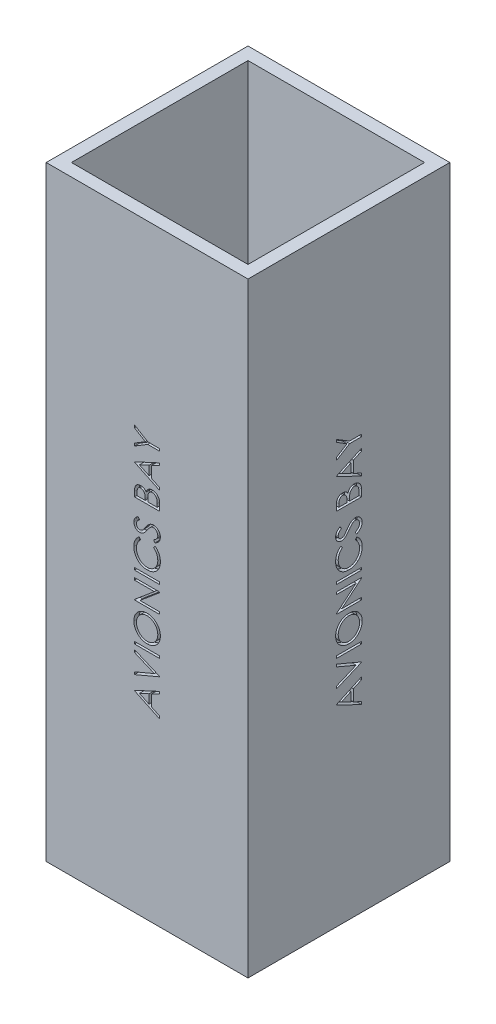
from build123d import *

# Parameters (mm, degrees)
SKETCH1_W           = 101.6
SKETCH1_H           = 101.6
SKETCH1_W_2         = 88.9
SKETCH1_H_2         = 88.9
BOSS_EXTRUDE1_DEPTH = 304.8
SKETCH6_W           = 12.7
SKETCH6_H           = 1.13974359
CUT_EXTRUDE1_DEPTH  = 2.54
CIRPATTERN1_COUNT   = 4


with BuildPart() as part:
    # Sketch1 → Boss-Extrude1 (new body)
    with BuildSketch(Plane(origin=(0, 0, 0), x_dir=(1, 0, 0), z_dir=(0, 1, 0))):
        Rectangle(SKETCH1_W, SKETCH1_H)
        Rectangle(SKETCH1_W_2, SKETCH1_H_2, mode=Mode.SUBTRACT)
    extrude(amount=BOSS_EXTRUDE1_DEPTH)

    # Sketch6 → Cut-Extrude1 (cut)
    with BuildSketch(Plane.ZY.offset(50.8)):
        Polygon((-6.35, 96.878205128), (6.35, 102.73974359), (6.35, 101.50078125), (2.279487179, 99.623257212), (2.279487179, 93.866025641), (6.35, 91.935076122), (6.35, 90.691025641), (-6.35, 96.715384615), align=None)
        Polygon((-3.874619391, 96.784074519), (0.976923077, 94.484234776), (0.976923077, 99.022856571), align=None, mode=Mode.SUBTRACT)
        Polygon((-6.35, 103.716666667), (-6.35, 104.937820513), (3.658373397, 109.171153846), (-6.35, 113.404487179), (-6.35, 114.625641026), (6.35, 109.252564103), (6.35, 109.08974359), align=None)
        with Locations((0, 117.637820513)):
            Rectangle(SKETCH6_W, SKETCH6_H)
        with BuildLine():
            add(Edge.make_bspline(
                [(-6.675641026, 126.918589744), (-6.669785071, 127.153776225), (-6.658283492, 127.615701878), (-6.567334124, 128.293959972), (-6.41764098, 128.94342251), (-6.206242297, 129.564462859), (-5.932190469, 130.154719051), (-5.599295982, 130.715858123), (-5.205535771, 131.246198399), (-4.756691829, 131.742089333), (-4.26513446, 132.194456748), (-3.738912975, 132.591411503), (-3.184643364, 132.926280299), (-2.60229672, 133.200406882), (-1.99323266, 133.415614417), (-1.354037691, 133.564081648), (-0.688898346, 133.658928646), (-0.235229152, 133.67001636), (-0.005088141, 133.675641026)],
                knots=[0, 0, 0, 0, 0.000705368, 0.001385402, 0.0020488, 0.002702076, 0.003349741, 0.00399766, 0.004656078, 0.005327949, 0.006001364, 0.006657226, 0.007302086, 0.007940532, 0.008585026, 0.009236039, 0.009906328, 0.010596447, 0.010596447, 0.010596447, 0.010596447], degree=3))
            add(Edge.make_bspline(
                [(-0.005088141, 133.675641026), (0.223356266, 133.670014467), (0.673646657, 133.658923867), (1.334584132, 133.564004689), (1.969850898, 133.414951949), (2.578031024, 133.203071444), (3.159194899, 132.928734508), (3.71388411, 132.593372735), (4.241511135, 132.197171355), (4.736454933, 131.746724924), (5.189213913, 131.254231132), (5.588564969, 130.730032068), (5.923579539, 130.175777236), (6.200766497, 129.597210358), (6.411489139, 128.98978834), (6.56490218, 128.357931404), (6.658807614, 127.698196983), (6.669968316, 127.248780089), (6.675641026, 127.020352564)],
                knots=[0, 0, 0, 0, 0.000685036, 0.001350284, 0.001998823, 0.002640075, 0.00327852, 0.003923381, 0.004581277, 0.005254856, 0.005928271, 0.006585666, 0.00722835, 0.007867883, 0.008506734, 0.009153393, 0.009816123, 0.010501158, 0.010501158, 0.010501158, 0.010501158], degree=3))
            add(Edge.make_bspline(
                [(6.675641026, 127.020352564), (6.670018965, 126.790212892), (6.658936386, 126.336546337), (6.563935289, 125.670569095), (6.415376844, 125.03093271), (6.203071175, 124.41946635), (5.928688652, 123.835829034), (5.594118477, 123.278879305), (5.19712685, 122.750852685), (4.746579565, 122.256126919), (4.256099934, 121.803465543), (3.730558494, 121.40882438), (3.180265837, 121.074178969), (2.603694821, 120.800717734), (2.003632729, 120.584220981), (1.376076825, 120.436520641), (0.724604903, 120.340958758), (0.281037815, 120.329946601), (0.055969551, 120.324358974)],
                knots=[0, 0, 0, 0, 0.000690119, 0.001360408, 0.002013897, 0.002657552, 0.003298299, 0.003945339, 0.004603236, 0.005276814, 0.005950229, 0.006602529, 0.007245213, 0.007879059, 0.008513962, 0.009155077, 0.009810248, 0.010485118, 0.010485118, 0.010485118, 0.010485118], degree=3))
            add(Edge.make_bspline(
                [(0.055969551, 120.324358974), (-0.095097562, 120.326298937), (-0.395326011, 120.33015439), (-0.841156245, 120.37656996), (-1.279816632, 120.443922419), (-1.710059786, 120.540449359), (-2.130832502, 120.666693407), (-2.545036699, 120.815653621), (-2.948474782, 120.997589631), (-3.343057946, 121.203259411), (-3.722635205, 121.4328094), (-4.081426835, 121.686358548), (-4.422443595, 121.955001171), (-4.736848437, 122.249508342), (-5.033787705, 122.560173729), (-5.308698135, 122.892036987), (-5.564058671, 123.243073131), (-5.794183909, 123.614792623), (-6.002315626, 123.998036078), (-6.180920628, 124.393103243), (-6.33421348, 124.794628516), (-6.45845876, 125.204492525), (-6.556546433, 125.621606869), (-6.623338831, 126.046881916), (-6.669872784, 126.479978863), (-6.673710006, 126.771757077), (-6.675641026, 126.918589744)],
                knots=[0, 0, 0, 0, 0.000453023, 0.000900331, 0.00134327, 0.001783953, 0.002221843, 0.002660465, 0.003103469, 0.003548398, 0.003994743, 0.004433047, 0.004865726, 0.005295975, 0.005724256, 0.006154227, 0.006587795, 0.007025471, 0.007464852, 0.007895214, 0.008325184, 0.00875333, 0.009179133, 0.00960951, 0.010044159, 0.010484467, 0.010484467, 0.010484467, 0.010484467], degree=3))
        make_face()
        with BuildLine():
            add(Edge.make_bspline(
                [(-5.373076923, 126.974559295), (-5.371612874, 126.854036083), (-5.368698771, 126.61414187), (-5.330103131, 126.257532198), (-5.275488499, 125.905504237), (-5.196168901, 125.558739209), (-5.093572448, 125.216509883), (-4.969833028, 124.878664322), (-4.820275395, 124.546360887), (-4.652079665, 124.22001472), (-4.461036223, 123.907163348), (-4.258166746, 123.607053335), (-4.035933534, 123.327490795), (-3.799142721, 123.064635323), (-3.545739327, 122.819140613), (-3.277387483, 122.591114952), (-2.992926494, 122.380745328), (-2.693527038, 122.19056345), (-2.380860728, 122.021316425), (-2.060904396, 121.869782467), (-1.729897889, 121.744166597), (-1.389906788, 121.644660114), (-1.042429358, 121.560201909), (-0.685572416, 121.507223472), (-0.320566176, 121.468247545), (-0.073887757, 121.465494862), (0.05088141, 121.464102564)],
                knots=[0, 0, 0, 0, 0.000361401, 0.000719348, 0.001074863, 0.001429731, 0.001785501, 0.002146095, 0.002508248, 0.002878058, 0.003246738, 0.003607323, 0.00396412, 0.004317168, 0.004668001, 0.005021764, 0.005372855, 0.005728561, 0.006084895, 0.00643885, 0.006789913, 0.007145683, 0.007501125, 0.007861666, 0.008227207, 0.008601324, 0.008601324, 0.008601324, 0.008601324], degree=3))
            add(Edge.make_bspline(
                [(0.05088141, 121.464102564), (0.234345869, 121.468739076), (0.595277215, 121.477860528), (1.124266852, 121.557384132), (1.63314324, 121.680852383), (2.118873279, 121.859858024), (2.583622971, 122.088215042), (3.025583679, 122.366764243), (3.444625029, 122.698056552), (3.837627676, 123.074154181), (4.19619396, 123.485407025), (4.511375607, 123.921887717), (4.776641272, 124.380142983), (4.998397407, 124.857531559), (5.165459253, 125.358129306), (5.284574271, 125.878726583), (5.361776101, 126.419334899), (5.369274234, 126.787728134), (5.373076923, 126.974559295)],
                knots=[0, 0, 0, 0, 0.000550108, 0.001082232, 0.001601154, 0.002118677, 0.00263181, 0.003152009, 0.003682843, 0.004231661, 0.004781633, 0.005317521, 0.005844193, 0.006367833, 0.006893982, 0.007424089, 0.007968455, 0.008528619, 0.008528619, 0.008528619, 0.008528619], degree=3))
            add(Edge.make_bspline(
                [(5.373076923, 126.974559295), (5.371352914, 127.100142838), (5.367933685, 127.349212721), (5.333446658, 127.719666375), (5.278253288, 128.083480379), (5.198393676, 128.43998253), (5.099767851, 128.789639923), (4.97743268, 129.131397518), (4.830782133, 129.465141802), (4.667344949, 129.792513872), (4.481684714, 130.106183548), (4.281550104, 130.404473162), (4.063238117, 130.683554059), (3.829627504, 130.946286203), (3.57700307, 131.19006041), (3.310282099, 131.417436835), (3.025217373, 131.624169109), (2.727044186, 131.813706266), (2.416657403, 131.985018365), (2.095821442, 132.132169161), (1.766257055, 132.257838985), (1.427722103, 132.3591431), (1.080978091, 132.438565908), (0.725528754, 132.493281802), (0.362093818, 132.531558287), (0.116280345, 132.534443183), (-0.007632212, 132.535897436)],
                knots=[0, 0, 0, 0, 0.00037666, 0.00074703, 0.001115112, 0.001479909, 0.001842294, 0.002204411, 0.002567866, 0.002935359, 0.003301431, 0.003660587, 0.004012239, 0.004363588, 0.004714421, 0.005064598, 0.005414184, 0.00576989, 0.006123991, 0.006476875, 0.006827938, 0.007181271, 0.007536139, 0.007894167, 0.008259708, 0.008631282, 0.008631282, 0.008631282, 0.008631282], degree=3))
            add(Edge.make_bspline(
                [(-0.007632212, 132.535897436), (-0.130697041, 132.534441969), (-0.374818801, 132.531554782), (-0.735719484, 132.493300659), (-1.088609709, 132.438506), (-1.432104078, 132.359538459), (-1.766290161, 132.257756476), (-2.090854054, 132.132253863), (-2.407005009, 131.984261543), (-2.713961172, 131.814414362), (-3.008510573, 131.623494815), (-3.290092515, 131.414870151), (-3.553442649, 131.184954519), (-3.804973342, 130.940256746), (-4.03965346, 130.674893764), (-4.256576238, 130.388819264), (-4.465515493, 130.089156128), (-4.650429047, 129.769127694), (-4.822051388, 129.44003162), (-4.968471586, 129.102031491), (-5.094225799, 128.759954443), (-5.196475173, 128.412432789), (-5.275184667, 128.059630794), (-5.330152005, 127.701753628), (-5.368685515, 127.340050484), (-5.371608475, 127.096776301), (-5.373076923, 126.974559295)],
                knots=[0, 0, 0, 0, 0.000369031, 0.00073204, 0.001087555, 0.001439943, 0.001788407, 0.002134718, 0.002482986, 0.00283486, 0.003186283, 0.003535331, 0.003885231, 0.004234241, 0.004587492, 0.004946738, 0.00531086, 0.005682608, 0.006054677, 0.006423813, 0.006786796, 0.007147444, 0.007509758, 0.007870298, 0.008233308, 0.008599795, 0.008599795, 0.008599795, 0.008599795], degree=3))
        make_face(mode=Mode.SUBTRACT)
        Polygon((6.35, 136.280769231), (-6.35, 136.280769231), (-6.35, 136.519911859), (3.645653045, 144.91025641), (-6.35, 144.91025641), (-6.35, 146.05), (6.35, 146.05), (6.35, 145.790504808), (-3.62275641, 137.420512821), (6.35, 137.420512821), align=None)
        with Locations((0, 149.876282051)):
            Rectangle(SKETCH6_W, SKETCH6_H)
        with BuildLine():
            Line((-4.01963141, 164.937179487), (-3.256410256, 163.939903846))
            add(Edge.make_bspline(
                [(-3.256410256, 163.939903846), (-3.341194225, 163.86876175), (-3.509619091, 163.727436708), (-3.746144204, 163.500084035), (-3.96766222, 163.263092265), (-4.175596423, 163.016791141), (-4.361589506, 162.755480687), (-4.540126766, 162.489117567), (-4.696442281, 162.208023627), (-4.887401238, 161.821298238), (-5.082322078, 161.313422851), (-5.249970827, 160.67630071), (-5.355686274, 160.010291597), (-5.36721364, 159.55602053), (-5.373076923, 159.324959936)],
                knots=[0, 0, 0, 0, 0.00033196, 0.000659444, 0.000983431, 0.001304932, 0.001625525, 0.001945168, 0.002266407, 0.002589534, 0.003238685, 0.003894034, 0.004563275, 0.005256052, 0.005256052, 0.005256052, 0.005256052], degree=3))
            add(Edge.make_bspline(
                [(-5.373076923, 159.324959936), (-5.371611116, 159.197657678), (-5.368693107, 158.944234648), (-5.330197138, 158.568138759), (-5.276090748, 158.199065687), (-5.195807431, 157.837255511), (-5.094306788, 157.483168771), (-4.973020274, 157.134490642), (-4.822961328, 156.796269264), (-4.657105476, 156.463826165), (-4.469772216, 156.145312206), (-4.265432984, 155.843944011), (-4.046387468, 155.560803099), (-3.811766703, 155.295730062), (-3.562803693, 155.048216165), (-3.296709232, 154.821376006), (-3.01632795, 154.612178829), (-2.721427006, 154.42181689), (-2.414752947, 154.250446937), (-2.09455485, 154.106351454), (-1.766315152, 153.980499435), (-1.427706865, 153.879347067), (-1.080980558, 153.799905176), (-0.72469984, 153.744982709), (-0.359540199, 153.706932881), (-0.112038264, 153.704028246), (0.012720353, 153.702564103)],
                knots=[0, 0, 0, 0, 0.000381746, 0.00075995, 0.001133062, 0.001500343, 0.001870765, 0.002237676, 0.002606812, 0.002979993, 0.003351741, 0.00371443, 0.004071661, 0.004424911, 0.004775707, 0.005123948, 0.005472996, 0.005824418, 0.006176292, 0.006525803, 0.006876866, 0.007230199, 0.007585067, 0.007943095, 0.008311168, 0.008685285, 0.008685285, 0.008685285, 0.008685285], degree=3))
            add(Edge.make_bspline(
                [(0.012720353, 153.702564103), (0.200426958, 153.707153439), (0.568963978, 153.716163992), (1.108848166, 153.796015543), (1.62655408, 153.918332475), (2.118576381, 154.098650853), (2.58901667, 154.325429822), (3.032169897, 154.608387446), (3.454528385, 154.937342282), (3.845862858, 155.315668985), (4.203321893, 155.730809638), (4.518103914, 156.176206293), (4.780503276, 156.650767193), (4.998856092, 157.149247901), (5.166701906, 157.675485571), (5.284863161, 158.228533553), (5.361941929, 158.807189083), (5.369321311, 159.202592333), (5.373076923, 159.403826122)],
                knots=[0, 0, 0, 0, 0.000562815, 0.001105012, 0.001633818, 0.002156121, 0.002673826, 0.003197534, 0.003730369, 0.00427735, 0.004827582, 0.005371763, 0.005910445, 0.006451621, 0.007001941, 0.007564319, 0.008146516, 0.008749895, 0.008749895, 0.008749895, 0.008749895], degree=3))
            add(Edge.make_bspline(
                [(5.373076923, 159.403826122), (5.366949065, 159.625541593), (5.354887975, 160.06193068), (5.252710128, 160.701894661), (5.087037112, 161.314527297), (4.855178937, 161.899861539), (4.553770606, 162.456247255), (4.188381165, 162.984555137), (3.755534929, 163.485231121), (3.425033292, 163.786298346), (3.256410256, 163.939903846)],
                knots=[0, 0, 0, 0, 0.000664826, 0.001308536, 0.001938654, 0.00256556, 0.003192755, 0.00383282, 0.004489298, 0.005173128, 0.005173128, 0.005173128, 0.005173128], degree=3))
            Line((3.256410256, 163.939903846), (4.011999199, 164.937179487))
            add(Edge.make_bspline(
                [(4.011999199, 164.937179487), (4.115549426, 164.856919532), (4.322153882, 164.696784061), (4.613478666, 164.437535279), (4.887251894, 164.164230312), (5.142106353, 163.876166654), (5.379096924, 163.572836575), (5.598352345, 163.25426791), (5.798709025, 162.920732587), (5.982746472, 162.574879839), (6.144785206, 162.215912717), (6.288375195, 161.846991365), (6.407251844, 161.465853771), (6.507808151, 161.075708271), (6.579509323, 160.673031297), (6.636606518, 160.26250367), (6.670480805, 159.840282994), (6.673905521, 159.555682198), (6.675641026, 159.411458333)],
                knots=[0, 0, 0, 0, 0.00039295, 0.000784017, 0.001168988, 0.001552873, 0.001937104, 0.002323107, 0.002712292, 0.003103781, 0.003497718, 0.003893163, 0.004290641, 0.004694796, 0.005100972, 0.005516895, 0.005937967, 0.006370579, 0.006370579, 0.006370579, 0.006370579], degree=3))
            add(Edge.make_bspline(
                [(6.675641026, 159.411458333), (6.674690367, 159.274865599), (6.672810557, 159.00477038), (6.642358978, 158.60599491), (6.60081279, 158.217775574), (6.538255743, 157.841221932), (6.464434852, 157.474279108), (6.365479149, 157.120273558), (6.254629316, 156.775721795), (6.124345507, 156.442008102), (5.977329645, 156.11884862), (5.811171703, 155.807285647), (5.627268936, 155.507462478), (5.429675042, 155.216431379), (5.212043118, 154.938491576), (4.977395615, 154.671234498), (4.726523405, 154.413161513), (4.545621508, 154.253494627), (4.454667468, 154.173217147)],
                knots=[0, 0, 0, 0, 0.000409666, 0.000810065, 0.001199174, 0.001580615, 0.001954827, 0.00232143, 0.002682661, 0.003040299, 0.003395496, 0.003747176, 0.004098847, 0.004450261, 0.004801913, 0.005157073, 0.005516877, 0.005880706, 0.005880706, 0.005880706, 0.005880706], degree=3))
            add(Edge.make_bspline(
                [(4.454667468, 154.173217147), (4.296671895, 154.044644771), (3.982588209, 153.789052255), (3.473598494, 153.461901295), (2.942643322, 153.182795524), (2.386647308, 152.954609118), (1.80539431, 152.779335337), (1.199819394, 152.656106475), (0.571133136, 152.576587079), (0.143559958, 152.567459908), (-0.073778045, 152.562820513)],
                knots=[0, 0, 0, 0, 0.000610709, 0.001214046, 0.001811469, 0.002408161, 0.003014189, 0.003629886, 0.004260364, 0.004912143, 0.004912143, 0.004912143, 0.004912143], degree=3))
            add(Edge.make_bspline(
                [(-0.073778045, 152.562820513), (-0.302216405, 152.568463644), (-0.751654617, 152.579566151), (-1.41123439, 152.673893752), (-2.04315518, 152.825636241), (-2.646237339, 153.041162094), (-3.223652928, 153.31441294), (-3.770991014, 153.651966653), (-4.291751972, 154.049901712), (-4.77803407, 154.505097172), (-5.222676864, 155.004270075), (-5.613859375, 155.538826914), (-5.93940579, 156.107721407), (-6.211534722, 156.704686183), (-6.420701774, 157.33419137), (-6.567126194, 157.994893881), (-6.658265445, 158.685552229), (-6.669786913, 159.156767316), (-6.675641026, 159.39619391)],
                knots=[0, 0, 0, 0, 0.000685036, 0.001347765, 0.001994424, 0.002631723, 0.003265569, 0.003907406, 0.004557186, 0.005228594, 0.005902557, 0.006560016, 0.007211953, 0.007865497, 0.008525192, 0.009197944, 0.009893113, 0.01061119, 0.01061119, 0.01061119, 0.01061119], degree=3))
            add(Edge.make_bspline(
                [(-6.675641026, 159.39619391), (-6.673890031, 159.542114516), (-6.670424115, 159.830949658), (-6.636678167, 160.258230506), (-6.580304858, 160.674192872), (-6.5039791, 161.079274223), (-6.407862207, 161.47464568), (-6.288069769, 161.859567565), (-6.145448455, 162.233097302), (-5.982581524, 162.595113545), (-5.799438593, 162.943172484), (-5.598179886, 163.277055612), (-5.379822309, 163.595431829), (-5.142130377, 163.896646351), (-4.887075716, 164.181067708), (-4.617645938, 164.452915028), (-4.326927265, 164.704275096), (-4.12225087, 164.859402575), (-4.01963141, 164.937179487)],
                knots=[0, 0, 0, 0, 0.000437698, 0.00086638, 0.001284824, 0.001696468, 0.002102476, 0.00250481, 0.002905006, 0.003301261, 0.003695, 0.004084185, 0.004470188, 0.004852417, 0.005234401, 0.005615774, 0.005999895, 0.006386133, 0.006386133, 0.006386133, 0.006386133], degree=3))
        make_face()
        with BuildLine():
            Line((3.900060096, 166.23974359), (3.256410256, 167.313341346))
            add(Edge.make_bspline(
                [(3.256410256, 167.313341346), (3.423558168, 167.413193236), (3.743807115, 167.604505602), (4.176543433, 167.923643391), (4.544343259, 168.254325669), (4.845066949, 168.599001251), (5.081827195, 168.955566263), (5.249475293, 169.3263484), (5.354036118, 169.710098171), (5.366736432, 169.971260323), (5.373076923, 170.101642628)],
                knots=[0, 0, 0, 0, 0.000583841, 0.001118616, 0.00161028, 0.002064766, 0.002487434, 0.002889373, 0.003281209, 0.003671854, 0.003671854, 0.003671854, 0.003671854], degree=3))
            add(Edge.make_bspline(
                [(5.373076923, 170.101642628), (5.369901903, 170.212969551), (5.363607418, 170.433675437), (5.305569139, 170.759226871), (5.210618635, 171.073820423), (5.081902947, 171.374328835), (4.923683382, 171.652790602), (4.737112822, 171.900890196), (4.521537218, 172.110383999), (4.284942628, 172.284056896), (4.031233879, 172.418443722), (3.769823052, 172.52001459), (3.497123393, 172.576899748), (3.313472359, 172.58543586), (3.220793269, 172.58974359)],
                knots=[0, 0, 0, 0, 0.000333749, 0.000661658, 0.00098843, 0.001317806, 0.001640301, 0.001947123, 0.002245767, 0.002538865, 0.00282455, 0.003104744, 0.003377672, 0.003655722, 0.003655722, 0.003655722, 0.003655722], degree=3))
            add(Edge.make_bspline(
                [(3.220793269, 172.58974359), (3.115018322, 172.584508847), (2.900812519, 172.573907922), (2.584236292, 172.480481264), (2.269594656, 172.337822667), (2.074931876, 172.203739618), (1.974198718, 172.134354968)],
                knots=[0, 0, 0, 0, 0.000316704, 0.000641359, 0.000982872, 0.001349121, 0.001349121, 0.001349121, 0.001349121], degree=3))
            add(Edge.make_bspline(
                [(1.974198718, 172.134354968), (1.90144819, 172.077501361), (1.748717556, 171.958144324), (1.521566328, 171.752774984), (1.286785255, 171.513014926), (1.03922007, 171.242145649), (0.780927013, 170.93971279), (0.5098905, 170.605599338), (0.231649187, 170.236953825), (0.045281334, 169.978202783), (-0.05088141, 169.844691506)],
                knots=[0, 0, 0, 0, 0.00027693, 0.00058138, 0.000917785, 0.001283326, 0.001682064, 0.002110776, 0.002573803, 0.003067412, 0.003067412, 0.003067412, 0.003067412], degree=3))
            add(Edge.make_bspline(
                [(-0.05088141, 169.844691506), (-0.146053714, 169.711073006), (-0.328015911, 169.455604608), (-0.598069742, 169.098340609), (-0.844971783, 168.778864986), (-1.071046341, 168.498597698), (-1.276324078, 168.257662018), (-1.458833743, 168.054159355), (-1.623511235, 167.893273734), (-1.730341247, 167.803809198), (-1.778305288, 167.763641827)],
                knots=[0, 0, 0, 0, 0.000492118, 0.000940893, 0.001343419, 0.001703394, 0.002021005, 0.002292935, 0.002523226, 0.002710868, 0.002710868, 0.002710868, 0.002710868], degree=3))
            add(Edge.make_bspline(
                [(-1.778305288, 167.763641827), (-1.853061333, 167.707508002), (-2.000079127, 167.5971133), (-2.229805018, 167.451233986), (-2.464519473, 167.328213563), (-2.705073148, 167.229205123), (-2.949658139, 167.149140748), (-3.200110695, 167.093475469), (-3.454730594, 167.059164567), (-3.626042223, 167.055620349), (-3.711798878, 167.053846154)],
                knots=[0, 0, 0, 0, 0.000280379, 0.000551403, 0.000815399, 0.001074307, 0.001330956, 0.00158648, 0.001843028, 0.00210018, 0.00210018, 0.00210018, 0.00210018], degree=3))
            add(Edge.make_bspline(
                [(-3.711798878, 167.053846154), (-3.846164323, 167.058581987), (-4.112023245, 167.067952428), (-4.500388447, 167.147205364), (-4.871193366, 167.272281321), (-5.220681509, 167.44756559), (-5.540071901, 167.673310696), (-5.832239357, 167.935689886), (-6.081208535, 168.245304478), (-6.295348186, 168.588070847), (-6.464690808, 168.961284292), (-6.587413997, 169.354196894), (-6.660310029, 169.76398427), (-6.670480481, 170.041990806), (-6.675641026, 170.183052885)],
                knots=[0, 0, 0, 0, 0.000402767, 0.000796926, 0.001183901, 0.001574148, 0.001965141, 0.002354126, 0.002748285, 0.003152792, 0.003563783, 0.00397416, 0.004384892, 0.004807973, 0.004807973, 0.004807973, 0.004807973], degree=3))
            add(Edge.make_bspline(
                [(-6.675641026, 170.183052885), (-6.670549285, 170.332734281), (-6.660423439, 170.630402805), (-6.570190732, 171.067557559), (-6.426581296, 171.490168611), (-6.258089803, 171.828624484), (-6.090878214, 172.094077708), (-5.938243775, 172.296316487), (-5.762888377, 172.502369213), (-5.561115259, 172.710021438), (-5.336960086, 172.92132312), (-5.088525366, 173.135300953), (-4.818049902, 173.353957403), (-4.624912741, 173.494577906), (-4.525901442, 173.566666667)],
                knots=[0, 0, 0, 0, 0.00044863, 0.000892182, 0.001333063, 0.001784748, 0.002022602, 0.002273448, 0.002544149, 0.002833827, 0.003141576, 0.003468021, 0.003817263, 0.004184633, 0.004184633, 0.004184633, 0.004184633], degree=3))
            Line((-4.525901442, 173.566666667), (-3.744871795, 172.536318109))
            add(Edge.make_bspline(
                [(-3.744871795, 172.536318109), (-3.825026824, 172.474107404), (-3.97938667, 172.354304132), (-4.195483741, 172.172345372), (-4.393146913, 172.001104738), (-4.564381231, 171.83110024), (-4.722009393, 171.675435779), (-4.854569572, 171.521670798), (-4.966250039, 171.375739107), (-5.085651319, 171.192234038), (-5.200429634, 170.959775153), (-5.301248892, 170.67040125), (-5.361060256, 170.366971662), (-5.369038173, 170.160416239), (-5.373076923, 170.055849359)],
                knots=[0, 0, 0, 0, 0.000304354, 0.000586115, 0.000847462, 0.001088545, 0.001309821, 0.001511814, 0.001697025, 0.001860738, 0.002167928, 0.002472049, 0.002777898, 0.00309148, 0.00309148, 0.00309148, 0.00309148], degree=3))
            add(Edge.make_bspline(
                [(-5.373076923, 170.055849359), (-5.368752177, 169.924621874), (-5.360412313, 169.671562032), (-5.2669317, 169.31312815), (-5.124800726, 168.988656041), (-4.919849343, 168.710532372), (-4.675507819, 168.480889971), (-4.396853518, 168.312714045), (-4.089090687, 168.212164614), (-3.874507915, 168.199857539), (-3.765224359, 168.193589744)],
                knots=[0, 0, 0, 0, 0.000392785, 0.000757449, 0.001103592, 0.001449623, 0.001786259, 0.002103452, 0.002418835, 0.002746151, 0.002746151, 0.002746151, 0.002746151], degree=3))
            add(Edge.make_bspline(
                [(-3.765224359, 168.193589744), (-3.697198882, 168.195097723), (-3.560200307, 168.198134688), (-3.358759769, 168.236942195), (-3.158381362, 168.289413133), (-2.959770314, 168.369853596), (-2.75842921, 168.481873603), (-2.551514272, 168.628819859), (-2.337243251, 168.813934503), (-2.197879003, 168.955726853), (-2.124298878, 169.030588942)],
                knots=[0, 0, 0, 0, 0.00020378, 0.000410399, 0.000613447, 0.00082462, 0.001051213, 0.001303192, 0.001584654, 0.001899472, 0.001899472, 0.001899472, 0.001899472], degree=3))
            add(Edge.make_bspline(
                [(-2.124298878, 169.030588942), (-2.099490242, 169.058388779), (-2.0405506, 169.124434829), (-1.94405861, 169.245178902), (-1.825031408, 169.404628484), (-1.677757431, 169.5986199), (-1.506918983, 169.830730041), (-1.314700447, 170.10098443), (-1.094861782, 170.406370564), (-0.94116442, 170.623075802), (-0.859895833, 170.737660256)],
                knots=[0, 0, 0, 0, 0.000111766, 0.000265529, 0.000463461, 0.000708709, 0.000996201, 0.001328024, 0.001703617, 0.002125051, 0.002125051, 0.002125051, 0.002125051], degree=3))
            add(Edge.make_bspline(
                [(-0.859895833, 170.737660256), (-0.759597115, 170.875494759), (-0.565382548, 171.142392169), (-0.273589467, 171.522150989), (0.011792861, 171.866475445), (0.28892344, 172.176599914), (0.555762092, 172.455502879), (0.81531225, 172.700372837), (1.06587182, 172.912320821), (1.384920328, 173.143614136), (1.780392633, 173.37715182), (2.265139205, 173.577391189), (2.751276848, 173.704780047), (3.077597552, 173.721324346), (3.238601763, 173.729487179)],
                knots=[0, 0, 0, 0, 0.000511383, 0.000990223, 0.001436481, 0.001852691, 0.002237729, 0.002594081, 0.002922749, 0.003221458, 0.003775598, 0.004295766, 0.004791239, 0.005273789, 0.005273789, 0.005273789, 0.005273789], degree=3))
            add(Edge.make_bspline(
                [(3.238601763, 173.729487179), (3.352459196, 173.727100276), (3.577963027, 173.722372823), (3.909106131, 173.668121419), (4.230644343, 173.588452913), (4.538285192, 173.469341873), (4.836964858, 173.321591781), (5.121056797, 173.136798957), (5.396080303, 172.921480341), (5.654325039, 172.674610946), (5.891685225, 172.404617397), (6.10195552, 172.118225682), (6.281317767, 171.818425471), (6.424162208, 171.501970131), (6.536635166, 171.17225923), (6.617899266, 170.828205505), (6.667829828, 170.469460435), (6.673008226, 170.22561731), (6.675641026, 170.101642628)],
                knots=[0, 0, 0, 0, 0.000341247, 0.000675867, 0.001004131, 0.001333458, 0.001663404, 0.002002138, 0.002348216, 0.002709912, 0.003072253, 0.003425393, 0.003774441, 0.004118267, 0.004465018, 0.004817984, 0.005177419, 0.005549167, 0.005549167, 0.005549167, 0.005549167], degree=3))
            add(Edge.make_bspline(
                [(6.675641026, 170.101642628), (6.673786166, 170.005720098), (6.670099808, 169.815083084), (6.637510594, 169.533108674), (6.591401949, 169.25683075), (6.518198939, 168.989716018), (6.429382315, 168.728323317), (6.320023842, 168.47378834), (6.188967649, 168.225992125), (6.039134719, 167.983529184), (5.864718678, 167.747081161), (5.661754709, 167.518609428), (5.435418335, 167.292103531), (5.182213046, 167.069170227), (4.899354459, 166.854673217), (4.591055869, 166.643463115), (4.256400464, 166.436569246), (4.021058782, 166.306577572), (3.900060096, 166.23974359)],
                knots=[0, 0, 0, 0, 0.00028766, 0.000571697, 0.000850676, 0.001127139, 0.001401486, 0.001678416, 0.001957221, 0.002241725, 0.002532773, 0.002837436, 0.003157645, 0.003492942, 0.003848621, 0.004221915, 0.004613751, 0.005028396, 0.005028396, 0.005028396, 0.005028396], degree=3))
        make_face()
        with BuildLine():
            Line((-6.35, 181.219230769), (-6.35, 183.697155449))
            add(Edge.make_bspline(
                [(-6.35, 183.697155449), (-6.349372317, 183.818454983), (-6.34815571, 184.053563668), (-6.32884905, 184.395419645), (-6.303182672, 184.715726817), (-6.260128703, 185.01391916), (-6.215487417, 185.291936968), (-6.149964695, 185.546957777), (-6.077592462, 185.781117702), (-5.966237959, 186.062295843), (-5.793303013, 186.381330972), (-5.536824054, 186.724234041), (-5.229326494, 187.02230631), (-4.878908769, 187.275756093), (-4.493409562, 187.479154935), (-4.081123013, 187.624443424), (-3.64898535, 187.717782282), (-3.352715027, 187.727260927), (-3.202984776, 187.732051282)],
                knots=[0, 0, 0, 0, 0.000363838, 0.000705208, 0.00102698, 0.001327407, 0.001608892, 0.001871129, 0.002116536, 0.002343771, 0.002777466, 0.0032008, 0.003623583, 0.004057151, 0.004494139, 0.004926249, 0.005365321, 0.005813951, 0.005813951, 0.005813951, 0.005813951], degree=3))
            add(Edge.make_bspline(
                [(-3.202984776, 187.732051282), (-3.062737383, 187.728061266), (-2.787138031, 187.720220508), (-2.384737295, 187.646157844), (-2.002077719, 187.528609812), (-1.639486801, 187.366153689), (-1.303714203, 187.156838065), (-0.995800058, 186.906048525), (-0.727381826, 186.604726897), (-0.577377362, 186.378855189), (-0.501181891, 186.264122596)],
                knots=[0, 0, 0, 0, 0.000420396, 0.000826117, 0.001222837, 0.001619092, 0.002014431, 0.002406622, 0.002806568, 0.003219445, 0.003219445, 0.003219445, 0.003219445], degree=3))
            add(Edge.make_bspline(
                [(-0.501181891, 186.264122596), (-0.445773816, 186.408382216), (-0.339764444, 186.684386606), (-0.152634166, 187.064428018), (0.051636421, 187.390663756), (0.271263785, 187.66946667), (0.511490195, 187.906655781), (0.774267381, 188.112075266), (1.059380217, 188.289664414), (1.365780824, 188.44079155), (1.690871704, 188.5595038), (2.030682193, 188.646755659), (2.383909628, 188.69836703), (2.623616838, 188.705407612), (2.745052083, 188.708974359)],
                knots=[0, 0, 0, 0, 0.000463447, 0.000886689, 0.001268545, 0.0016162, 0.001949007, 0.002278795, 0.002614805, 0.002954998, 0.003301897, 0.00365114, 0.00400589, 0.004370127, 0.004370127, 0.004370127, 0.004370127], degree=3))
            add(Edge.make_bspline(
                [(2.745052083, 188.708974359), (2.869029524, 188.705430578), (3.112958611, 188.69845809), (3.471291465, 188.646993984), (3.813764183, 188.559915894), (4.142434121, 188.439765244), (4.456612174, 188.284030002), (4.755160179, 188.091766128), (5.038699261, 187.865672621), (5.307729832, 187.610150413), (5.553901262, 187.325390902), (5.765525674, 187.011567593), (5.947492508, 186.677277716), (6.095643415, 186.318247692), (6.209941742, 185.935394053), (6.289576238, 185.528929837), (6.343323875, 185.099524432), (6.347736865, 184.804846892), (6.35, 184.653725962)],
                knots=[0, 0, 0, 0, 0.000371861, 0.000731647, 0.001083355, 0.001430255, 0.001779543, 0.002133105, 0.002493475, 0.002865962, 0.003244832, 0.003620227, 0.003999302, 0.004384828, 0.004783241, 0.005195859, 0.005626281, 0.006079382, 0.006079382, 0.006079382, 0.006079382], degree=3))
            Line((6.35, 184.653725962), (6.35, 181.219230769))
            Line((6.35, 181.219230769), (-6.35, 181.219230769))
        make_face()
        with BuildLine():
            Line((-5.047435897, 182.358974359), (-0.976923077, 182.358974359))
            Line((-0.976923077, 182.358974359), (-0.976923077, 183.124739583))
            add(Edge.make_bspline(
                [(-0.976923077, 183.124739583), (-0.978374226, 183.236676641), (-0.981178141, 183.452961848), (-0.989210049, 183.766179755), (-1.011700083, 184.056919118), (-1.034183694, 184.324678018), (-1.070739951, 184.569035007), (-1.114254566, 184.789448052), (-1.160274294, 184.989378525), (-1.238545357, 185.219930907), (-1.354184303, 185.481489371), (-1.533820739, 185.760139099), (-1.747610778, 186.006932087), (-1.996602328, 186.212835745), (-2.267797908, 186.382839956), (-2.558816675, 186.501933252), (-2.863802254, 186.581329207), (-3.073579537, 186.588610711), (-3.180088141, 186.592307692)],
                knots=[0, 0, 0, 0, 0.000335856, 0.000648942, 0.000939679, 0.001210548, 0.001454845, 0.001680365, 0.001884605, 0.002069641, 0.0024101, 0.002739663, 0.003060599, 0.003385683, 0.003705519, 0.004016874, 0.004326007, 0.004644839, 0.004644839, 0.004644839, 0.004644839], degree=3))
            add(Edge.make_bspline(
                [(-3.180088141, 186.592307692), (-3.250585181, 186.590430592), (-3.388872822, 186.586748455), (-3.591119209, 186.555496211), (-3.781156629, 186.504859278), (-3.960808966, 186.436283222), (-4.125611427, 186.342598152), (-4.283438701, 186.234004849), (-4.424837705, 186.099930997), (-4.556615938, 185.948415641), (-4.674557016, 185.77505505), (-4.77225292, 185.576114166), (-4.860797869, 185.356735914), (-4.926345062, 185.110968444), (-4.983983541, 184.84390414), (-5.020198184, 184.551926853), (-5.043502651, 184.236886782), (-5.046095572, 184.018603582), (-5.047435897, 183.905769231)],
                knots=[0, 0, 0, 0, 0.000211403, 0.00041469, 0.000612163, 0.000800665, 0.000989698, 0.001179568, 0.001373986, 0.00157239, 0.001781252, 0.00200084, 0.002236108, 0.002489814, 0.002762742, 0.003055266, 0.00337156, 0.003710008, 0.003710008, 0.003710008, 0.003710008], degree=3))
            Line((-5.047435897, 183.905769231), (-5.047435897, 182.358974359))
        make_face(mode=Mode.SUBTRACT)
        with BuildLine():
            Line((0.325641026, 182.358974359), (5.047435897, 182.358974359))
            Line((5.047435897, 182.358974359), (5.047435897, 183.982091346))
            add(Edge.make_bspline(
                [(5.047435897, 183.982091346), (5.045904986, 184.098262155), (5.042954355, 184.322166073), (5.036034513, 184.645699445), (5.009857802, 184.944782361), (4.985709904, 185.220358318), (4.944418036, 185.471695937), (4.905449249, 185.700728521), (4.847602867, 185.903696342), (4.768099821, 186.141215651), (4.640825315, 186.406707339), (4.454878463, 186.696841966), (4.225391341, 186.949834864), (3.964393202, 187.16700565), (3.681391572, 187.346224413), (3.380086158, 187.474830829), (3.066336778, 187.554751442), (2.852362575, 187.564394611), (2.745052083, 187.569230769)],
                knots=[0, 0, 0, 0, 0.000348575, 0.000671832, 0.000970368, 0.00124908, 0.001501302, 0.001734317, 0.001945399, 0.00213366, 0.002485313, 0.002825429, 0.003164106, 0.003505476, 0.003841486, 0.004165184, 0.004484806, 0.004806367, 0.004806367, 0.004806367, 0.004806367], degree=3))
            add(Edge.make_bspline(
                [(2.745052083, 187.569230769), (2.677946231, 187.568231973), (2.54481695, 187.566250491), (2.34920062, 187.536231529), (2.159617461, 187.492803605), (1.975277451, 187.435607779), (1.799280024, 187.355651098), (1.630950229, 187.257630908), (1.466897116, 187.145429385), (1.256812893, 186.972323658), (1.01776619, 186.716863765), (0.786615655, 186.35382675), (0.597190031, 185.943319967), (0.517108985, 185.644887606), (0.475741186, 185.49072516)],
                knots=[0, 0, 0, 0, 0.000201126, 0.000399009, 0.000592174, 0.000784466, 0.000976909, 0.00117066, 0.001368248, 0.001572487, 0.001986491, 0.00241129, 0.002858707, 0.003336803, 0.003336803, 0.003336803, 0.003336803], degree=3))
            add(Edge.make_bspline(
                [(0.475741186, 185.49072516), (0.463204167, 185.42893387), (0.436021324, 185.294957606), (0.407327657, 185.0764901), (0.381764154, 184.82707709), (0.362855097, 184.54614265), (0.343309639, 184.23333134), (0.33570843, 183.887975093), (0.326639687, 183.511484265), (0.325982428, 183.2502548), (0.325641026, 183.114563301)],
                knots=[0, 0, 0, 0, 0.000189102, 0.000410011, 0.000660625, 0.000941212, 0.001254639, 0.001600782, 0.001977382, 0.002384441, 0.002384441, 0.002384441, 0.002384441], degree=3))
            Line((0.325641026, 183.114563301), (0.325641026, 182.358974359))
        make_face(mode=Mode.SUBTRACT)
        Polygon((-6.35, 196.524358974), (6.35, 202.385897436), (6.35, 201.146935096), (2.279487179, 199.269411058), (2.279487179, 193.512179487), (6.35, 191.581229968), (6.35, 190.337179487), (-6.35, 196.361538462), align=None)
        Polygon((-3.874619391, 196.430228365), (0.976923077, 194.130388622), (0.976923077, 198.669010417), align=None, mode=Mode.SUBTRACT)
        Polygon((-6.35, 203.362820513), (-6.35, 204.667928686), (-0.89296875, 208.005749199), (-6.35, 211.338481571), (-6.35, 212.643589744), (0.312920673, 208.573076923), (6.35, 208.573076923), (6.35, 207.433333333), (0.312920673, 207.433333333), align=None)
    cut_extrude1 = extrude(amount=-CUT_EXTRUDE1_DEPTH, mode=Mode.SUBTRACT)

    # CirPattern1: Cut-Extrude1 ×4 about axis
    cirpattern1_axis = Axis((0, 0, 0), (0, 1, 0))
    for i in range(1, CIRPATTERN1_COUNT):
        add(cut_extrude1.rotate(cirpattern1_axis, i * 360 / CIRPATTERN1_COUNT), mode=Mode.SUBTRACT)


solid = part.part
